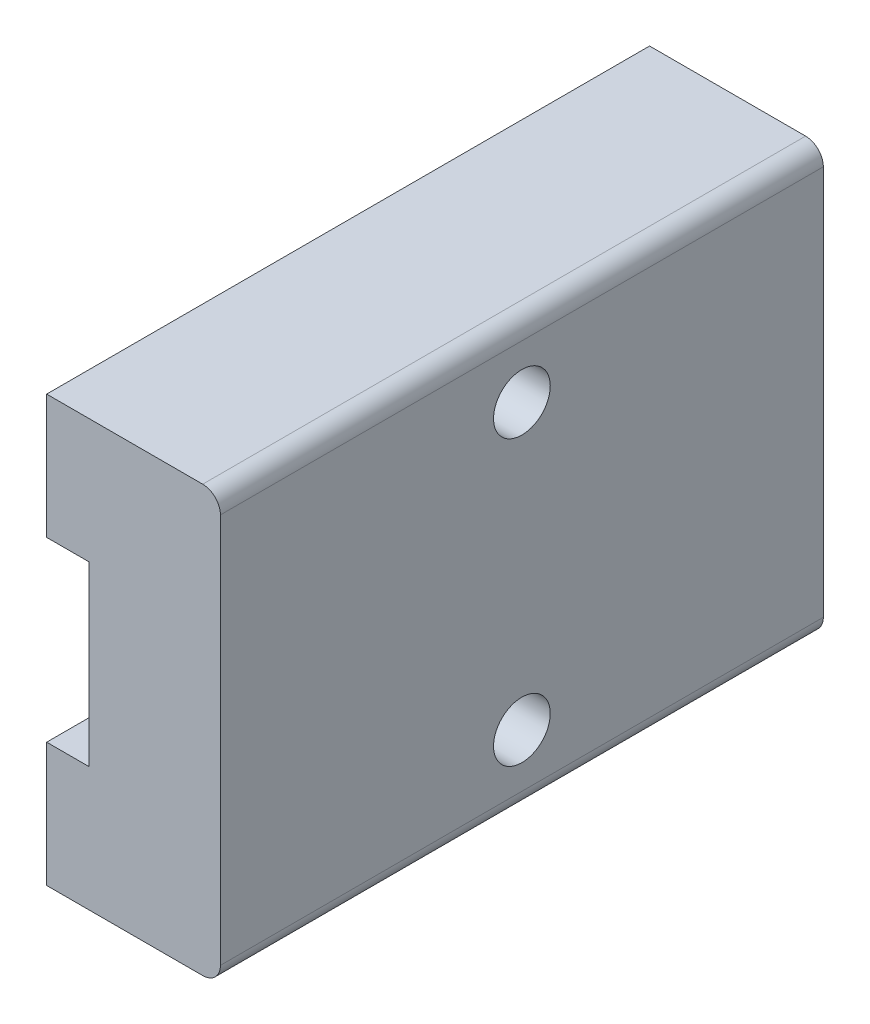
from build123d import *

# Parameters (mm, degrees)
SKETCH_1_W             = 4.9
SKETCH_1_H             = 12
EXTRUDE_1_DEPTH        = 17
SKETCH_2_W             = 1.2
SKETCH_2_H             = 5
CUT_EXTRUDE_1_DEPTH    = 18
FILLET_1_R             = 0.5
HOLE_WIZARD_M2_1_D     = 1.6
HOLE_WIZARD_M2_1_DEPTH = 2.2
HOLE_WIZARD_M2_1_TIP   = 0.480688495


with BuildPart() as part:
    # 草图1 → 凸台-拉伸1 (new body)
    with BuildSketch(Plane.XY):
        Rectangle(SKETCH_1_W, SKETCH_1_H)
    extrude(amount=EXTRUDE_1_DEPTH)

    # 草图2 → 切除-拉伸1 (cut, through all)
    with BuildSketch(Plane.XY.offset(17)):
        with Locations((-1.85, 0)):
            Rectangle(SKETCH_2_W, SKETCH_2_H)
    extrude(amount=-CUT_EXTRUDE_1_DEPTH, mode=Mode.SUBTRACT)

    # 圆角1
    fillet_1_edges = [part.edges().sort_by_distance(p)[0] for p in [
        (2.45, 6, 8.5),
        (2.45, -6, 8.5),
    ]]
    fillet(fillet_1_edges, radius=FILLET_1_R)

    # M2 螺纹孔1
    with Locations(Plane(origin=(2.45, 0, 0), x_dir=(0, 0, -1), z_dir=(1, 0, 0))):
        with Locations((-8.5, 4), (-8.5, -4)):
            Hole(HOLE_WIZARD_M2_1_D / 2, depth=HOLE_WIZARD_M2_1_DEPTH)
            with Locations((0, 0, -(HOLE_WIZARD_M2_1_DEPTH + HOLE_WIZARD_M2_1_TIP / 2))):  # 118° drill point
                Cone(0, HOLE_WIZARD_M2_1_D / 2, HOLE_WIZARD_M2_1_TIP, mode=Mode.SUBTRACT)


solid = part.part
